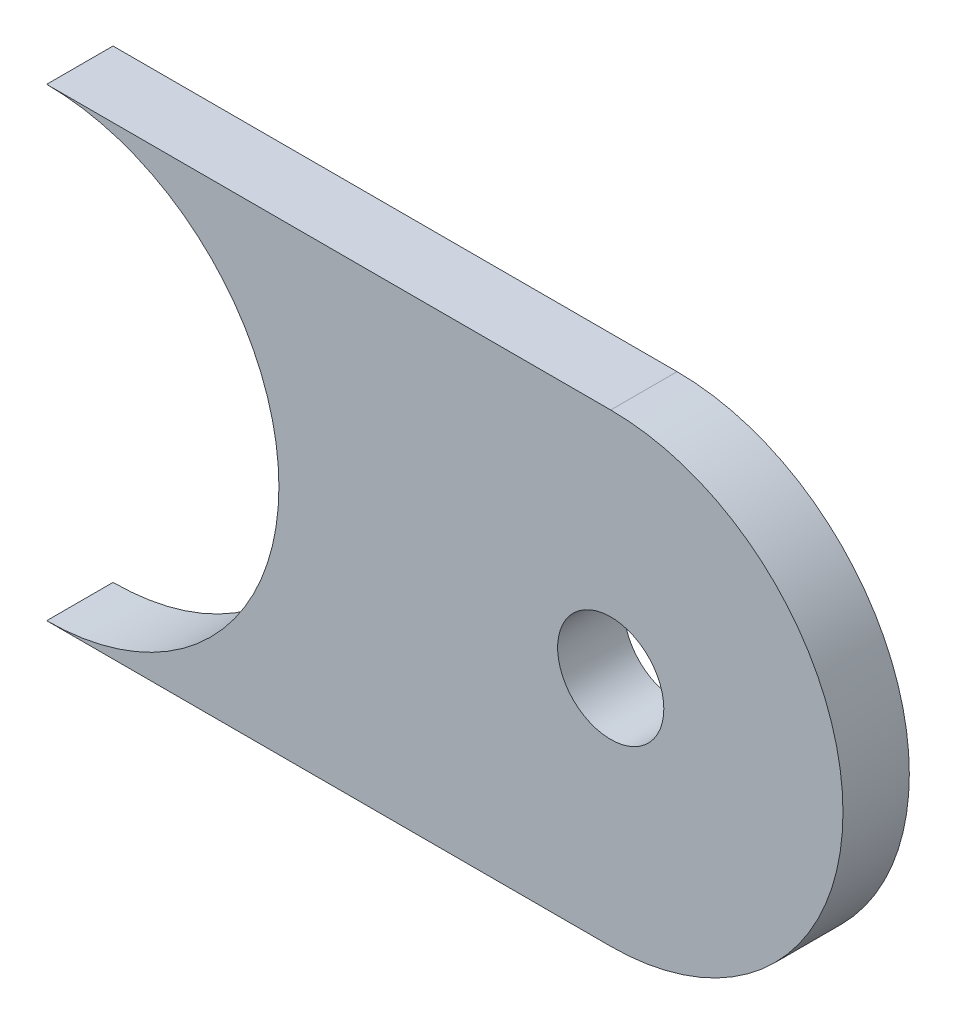
from build123d import *

# Parameters (mm, degrees)
SKETCH1_R           = 4
BOSS_EXTRUDE1_DEPTH = 5


with BuildPart() as part:
    # Sketch1 → Boss-Extrude1 (new body)
    with BuildSketch(Plane.XY):
        with BuildLine():
            Line((-39.868107623, 25.032533821), (2.631892377, 25.032533821))
            ThreePointArc((2.631892377, 25.032533821), (20.131892377, 7.532533821), (2.631892377, -9.967466179))
            Line((2.631892377, -9.967466179), (-39.868107623, -9.967466179))
            ThreePointArc((-39.868107623, -9.967466179), (-22.368107623, 7.532533821), (-39.868107623, 25.032533821))
        make_face()
        with Locations((2.631892377, 7.532533821)):
            Circle(SKETCH1_R, mode=Mode.SUBTRACT)
    extrude(amount=BOSS_EXTRUDE1_DEPTH)


solid = part.part
